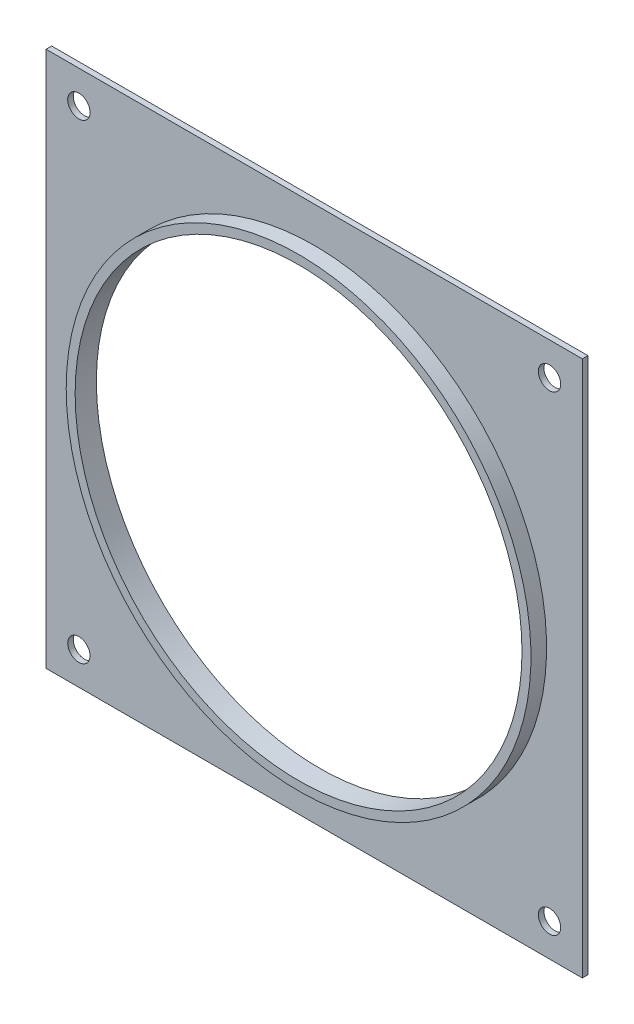
from build123d import *

# Parameters (mm, degrees)
SKETCH1_W           = 152.4
SKETCH1_H           = 152.4
SKETCH1_R           = 63.5
BOSS_EXTRUDE1_DEPTH = 1.5875
SKETCH2_R           = 66.04
SKETCH2_R_2         = 63.5
BOSS_EXTRUDE2_DEPTH = 4.445
SKETCH3_R           = 3.175
CUT_EXTRUDE1_DEPTH  = 1.5875


with BuildPart() as part:
    # Sketch1 → Boss-Extrude1 (new body)
    with BuildSketch(Plane.XY):
        Rectangle(SKETCH1_W, SKETCH1_H)
        Circle(SKETCH1_R, mode=Mode.SUBTRACT)
    extrude(amount=BOSS_EXTRUDE1_DEPTH)

    # Sketch2 → Boss-Extrude2 (add)
    with BuildSketch(Plane.XY.offset(1.5875)):
        Circle(SKETCH2_R)
        Circle(SKETCH2_R_2, mode=Mode.SUBTRACT)
    extrude(amount=BOSS_EXTRUDE2_DEPTH)

    # Sketch3 → Cut-Extrude1 (cut)
    with BuildSketch(Plane.XY.offset(1.5875)):
        with Locations((66.8782, -66.8782)):
            Circle(SKETCH3_R)
        with Locations((-66.8782, -66.8782)):
            Circle(SKETCH3_R)
        with Locations((-66.8782, 66.8782)):
            Circle(SKETCH3_R)
        with Locations((66.8782, 66.8782)):
            Circle(SKETCH3_R)
    extrude(amount=-CUT_EXTRUDE1_DEPTH, mode=Mode.SUBTRACT)


solid = part.part
